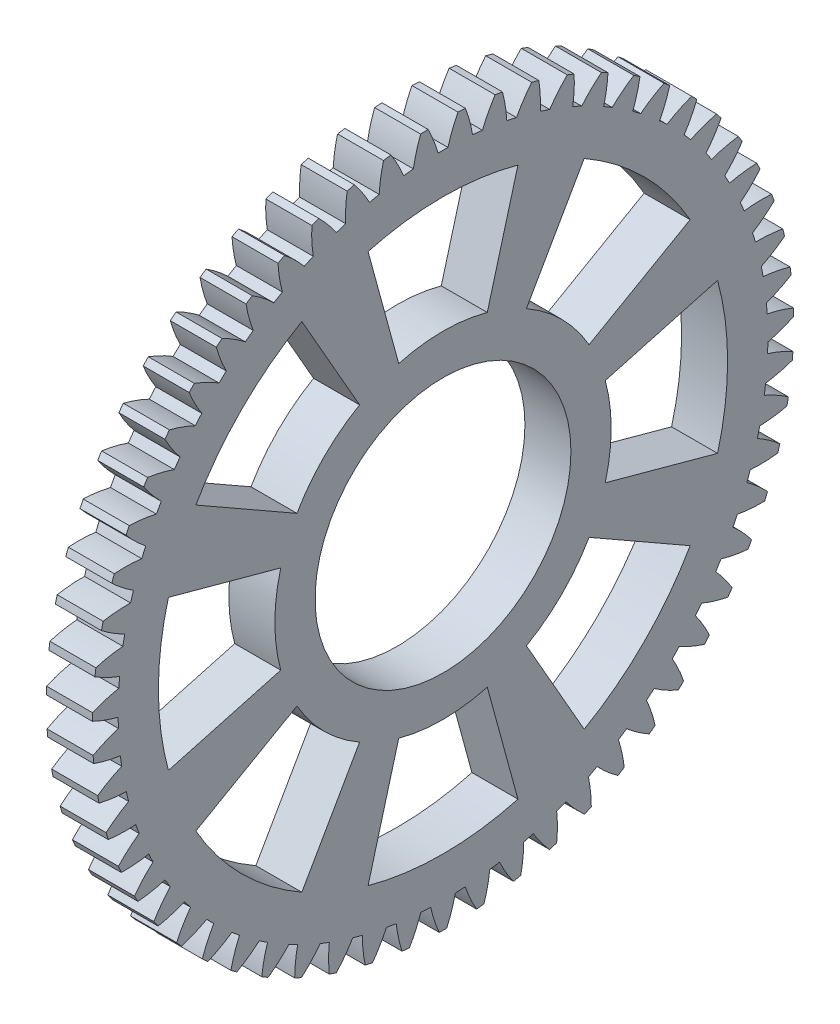
from build123d import *

# Parameters (mm, degrees)
BASPROSKE_W        = 4
BASPROSKE_H        = 30.5
TOOTHCUT_DEPTH     = 44.318587235
TEETHCUTS_COUNT    = 59
TEETHCUTS_ANGLE    = 353.898305085
BORSKE_R           = 4
BORE_DEPTH         = 50.0000508
SKETCH1_R          = 11.125
CUT_EXTRUDE1_DEPTH = 10
CUT_EXTRUDE2_DEPTH = 10
CIRPATTERN1_COUNT  = 8


with BuildPart() as part:
    # BasProSke → Base-Revolve (revolve)
    with BuildSketch(Plane(origin=(0, 0, 0), x_dir=(1, 0, 0), z_dir=(0, 1, 0)), mode=Mode.PRIVATE) as base_revolve_sk:
        with Locations((2, 15.25)):
            Rectangle(BASPROSKE_W, BASPROSKE_H)
    revolve(base_revolve_sk.sketch.rotate(Axis((-10, 0, 0), (1, 0, 0)), 180), axis=Axis((-10, 0, 0), (1, 0, 0)))

    # TooCutSke → ToothCut (cut, through all)
    with BuildSketch(Plane(origin=(0, 0, 0), x_dir=(0, 0, -1), z_dir=(1, 0, 0))):
        with BuildLine():
            ThreePointArc((0.430794105, 28.245715028), (0, 28.249), (-0.430794105, 28.245715028))
            ThreePointArc((-0.430794105, 28.245715028), (-0.814615912, 29.394097581), (-1.314100174, 30.49710127))
            ThreePointArc((-1.314100174, 30.49710127), (0, 30.5254), (1.314100174, 30.49710127))
            ThreePointArc((1.314100174, 30.49710127), (0.814615912, 29.394097581), (0.430794105, 28.245715028))
        make_face()
    toothcut = extrude(amount=TOOTHCUT_DEPTH, mode=Mode.SUBTRACT)

    # TeethCuts: ToothCut ×59 about axis
    teethcuts_axis = Axis((-10, 0, 0), (1, 0, 0))
    for i in range(1, TEETHCUTS_COUNT):
        add(toothcut.rotate(teethcuts_axis, i * TEETHCUTS_ANGLE / (TEETHCUTS_COUNT - 1)), mode=Mode.SUBTRACT)

    # BorSke → Bore (cut, symmetric)
    with BuildSketch(Plane(origin=(0, 0, 0), x_dir=(0, 0, -1), z_dir=(1, 0, 0))):
        with Locations(Location((0, 0, 0), (0, 0, 180))):
            Circle(BORSKE_R)
    extrude(amount=BORE_DEPTH, both=True, mode=Mode.SUBTRACT)

    # Sketch1 → Cut-Extrude1 (cut)
    with BuildSketch(Plane(origin=(4, 0, 0), x_dir=(0, 0, -1), z_dir=(1, 0, 0))):
        Circle(SKETCH1_R)
    extrude(amount=-CUT_EXTRUDE1_DEPTH, mode=Mode.SUBTRACT)

    # Sketch2 → Cut-Extrude2 (cut)
    with BuildSketch(Plane(origin=(4, 0, 0), x_dir=(0, 0, -1), z_dir=(1, 0, 0))):
        with BuildLine():
            ThreePointArc((-3.850371699, 14.109048968), (-1.942393349, 14.495438354), (0, 14.625))
            Line((0, 14.625), (0, 24.749))
            ThreePointArc((0, 24.749), (-3.286994393, 24.529750689), (-6.515750371, 23.875887378))
            Line((-6.515750371, 23.875887378), (-3.850371699, 14.109048968))
        make_face()
        with BuildLine():
            Line((0, 24.749), (0, 14.625))
            ThreePointArc((0, 14.625), (1.942393349, 14.495438354), (3.850371699, 14.109048968))
            Line((3.850371699, 14.109048968), (6.515750371, 23.875887378))
            ThreePointArc((6.515750371, 23.875887378), (3.286994393, 24.529750689), (0, 24.749))
        make_face()
    cut_extrude2 = extrude(amount=-CUT_EXTRUDE2_DEPTH, mode=Mode.SUBTRACT)

    # CirPattern1: Cut-Extrude2 ×8 about axis
    cirpattern1_axis = Axis((0, 0, 0), (1, 0, 0))
    for i in range(1, CIRPATTERN1_COUNT):
        add(cut_extrude2.rotate(cirpattern1_axis, i * 360 / CIRPATTERN1_COUNT), mode=Mode.SUBTRACT)


solid = part.part
